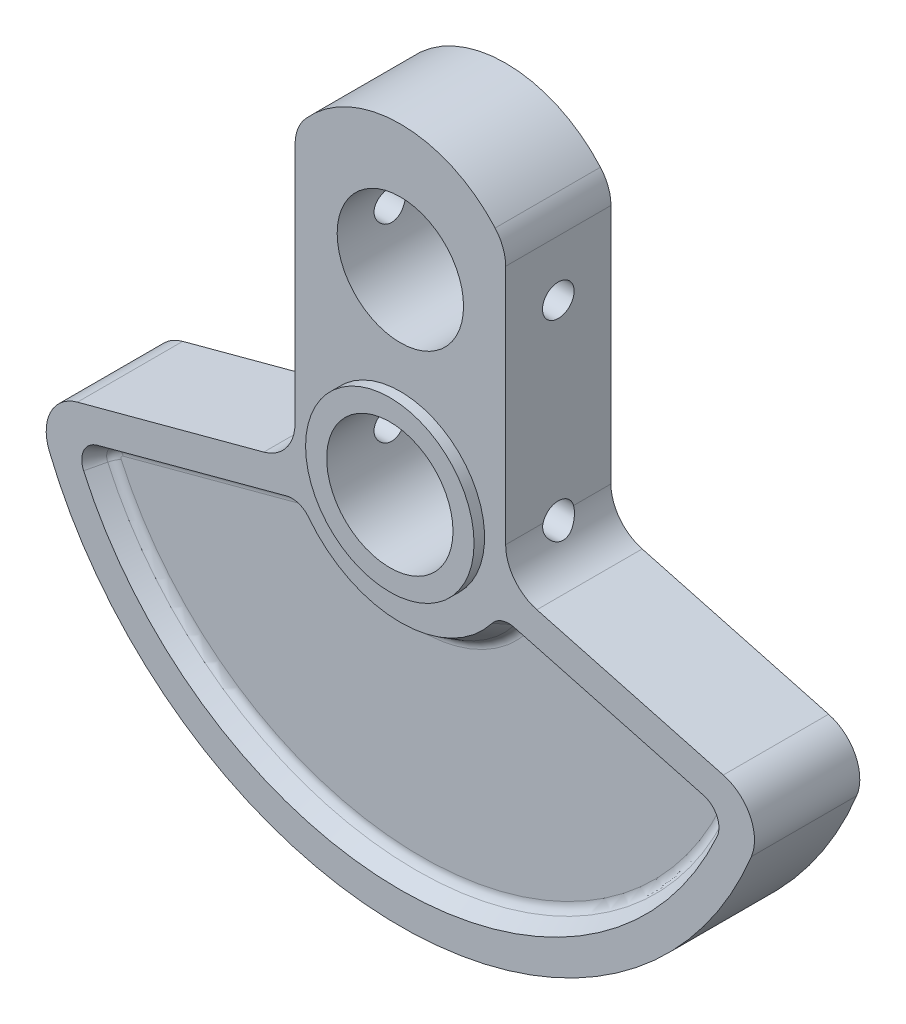
from build123d import *

# Parameters (mm, degrees)
SKETCH1_R            = 6
BOSS_EXTRUDE1_DEPTH  = 5
CUT_EXTRUDE1_DEPTH   = 2
CUT_EXTRUDE1_DRAFT   = -30
FILLET1_R            = 1
MIRROR2_COPY_1_DEPTH = 2
MIRROR2_COPY_1_DRAFT = -30
FILLET1_OF_MIRROR2_R = 1
SKETCH3_R            = 8
SKETCH3_R_2          = 6
BOSS_EXTRUDE2_DEPTH  = 1
SKETCH4_R            = 8
SKETCH4_R_2          = 6
BOSS_EXTRUDE3_DEPTH  = 1
SKETCH5_R            = 1.5
CUT_EXTRUDE2_DEPTH   = 57.883602865


with BuildPart() as part:
    # Sketch1 → Boss-Extrude1 (new, symmetric)
    with BuildSketch(Plane.XY):
        with BuildLine():
            Line((-10, 23.291502622), (-10, 0.389816028))
            ThreePointArc((-10, 0.389816028), (-10.826586639, -2.045229688), (-12.96472382, -3.473887278))
            Line((-12.96472382, -3.473887278), (-30.667194256, -8.217249935))
            ThreePointArc((-30.667194256, -8.217249935), (-33.214466382, -10.301810854), (-33.335907835, -13.591072395))
            ThreePointArc((-33.335907835, -13.591072395), (0, -36), (33.335907835, -13.591072395))
            ThreePointArc((33.335907835, -13.591072395), (33.214466382, -10.301810854), (30.667194256, -8.217249935))
            Line((30.667194256, -8.217249935), (12.96472382, -3.473887278))
            ThreePointArc((12.96472382, -3.473887278), (10.826586639, -2.045229688), (10, 0.389816028))
            Line((10, 0.389816028), (10, 23.291502622))
            ThreePointArc((10, 23.291502622), (9.741657387, 24.705716185), (9, 25.937253933))
            ThreePointArc((9, 25.937253933), (0, 30), (-9, 25.937253933))
            ThreePointArc((-9, 25.937253933), (-9.741657387, 24.705716185), (-10, 23.291502622))
        make_face()
        Circle(SKETCH1_R, mode=Mode.SUBTRACT)
        with Locations((0, 18)):
            Circle(SKETCH1_R, mode=Mode.SUBTRACT)
    extrude(amount=BOSS_EXTRUDE1_DEPTH, both=True)


with BuildPart() as cut_extrude1_tool:
    # Sketch2 → Cut-Extrude1 (with draft: the straight prism first)
    with BuildSketch(Plane.XY.offset(5)):
        with BuildLine():
            ThreePointArc((-28.775190686, -10.816117648), (-30.064835096, -11.891388911), (-30.080620505, -13.570418933))
            ThreePointArc((-30.080620505, -13.570418933), (0, -33), (30.080620505, -13.570418933))
            ThreePointArc((30.080620505, -13.570418933), (30.064835096, -11.891388911), (28.775190686, -10.816117648))
            Line((28.775190686, -10.816117648), (10.81465278, -6.00360602))
            ThreePointArc((10.81465278, -6.00360602), (9.656117125, -6.040925986), (8.712858584, -6.714618031))
            ThreePointArc((8.712858584, -6.714618031), (0, -11), (-8.712858584, -6.714618031))
            ThreePointArc((-8.712858584, -6.714618031), (-9.656117125, -6.040925986), (-10.81465278, -6.00360602))
            Line((-10.81465278, -6.00360602), (-28.775190686, -10.816117648))
        make_face()
    extrude(amount=-CUT_EXTRUDE1_DEPTH)
    # Cut-Extrude1: the draft: its side faces are tilted about the plane it starts from
    cut_extrude1_sides = [cut_extrude1_tool.faces().sort_by_distance(p)[0] for p in [
        (-9.656117125, -6.040925986, 4),
        (-19.794921733, -8.409861834, 4),
        (-30.064835096, -11.891388911, 4),
        (0, -33, 4),
        (30.064835096, -11.891388911, 4),
        (19.794921733, -8.409861834, 4),
        (9.656117125, -6.040925986, 4),
        (0, -11, 4),
    ]]
    draft(cut_extrude1_sides, Plane.XY.offset(5), CUT_EXTRUDE1_DRAFT)


with BuildPart() as part_1:
    add(part.part)

    # Cut-Extrude1: cut by cut_extrude1_tool
    add(cut_extrude1_tool.part, mode=Mode.SUBTRACT)

    # Fillet1
    fillet1_edges = [part_1.edges().sort_by_distance(p)[0] for p in [
        (29.021400058, -12.385935829, 3),
        (0, -31.845299462, 3),
        (-29.021400058, -12.385935829, 3),
        (-19.496063242, -9.525216906, 3),
        (-10.026139506, -7.134734365, 3),
        (0, -12.154700538, 3),
        (10.026139506, -7.134734365, 3),
        (19.496063242, -9.525216906, 3),
    ]]
    fillet(fillet1_edges, radius=FILLET1_R)


with BuildPart() as mirror2_copy_1_tool:
    # Mirror2 copy 1 sketch → Mirror2 copy 1 (with draft: the straight prism first)
    with BuildSketch(Plane(origin=(0, 0, -5), x_dir=(1, 0, 0), z_dir=(0, 0, -1))):
        with BuildLine():
            ThreePointArc((-28.775190686, 10.816117648), (-30.064835096, 11.891388911), (-30.080620505, 13.570418933))
            ThreePointArc((-30.080620505, 13.570418933), (0, 33), (30.080620505, 13.570418933))
            ThreePointArc((30.080620505, 13.570418933), (30.064835096, 11.891388911), (28.775190686, 10.816117648))
            Line((28.775190686, 10.816117648), (10.81465278, 6.00360602))
            ThreePointArc((10.81465278, 6.00360602), (9.656117125, 6.040925986), (8.712858584, 6.714618031))
            ThreePointArc((8.712858584, 6.714618031), (0, 11), (-8.712858584, 6.714618031))
            ThreePointArc((-8.712858584, 6.714618031), (-9.656117125, 6.040925986), (-10.81465278, 6.00360602))
            Line((-10.81465278, 6.00360602), (-28.775190686, 10.816117648))
        make_face()
    extrude(amount=-MIRROR2_COPY_1_DEPTH)
    # Mirror2 copy 1: the draft: its side faces are tilted about the plane it starts from
    mirror2_copy_1_sides = [mirror2_copy_1_tool.faces().sort_by_distance(p)[0] for p in [
        (-9.656117125, -6.040925986, -4),
        (-19.794921733, -8.409861834, -4),
        (-30.064835096, -11.891388911, -4),
        (0, -33, -4),
        (30.064835096, -11.891388911, -4),
        (19.794921733, -8.409861834, -4),
        (9.656117125, -6.040925986, -4),
        (0, -11, -4),
    ]]
    draft(mirror2_copy_1_sides, Plane(origin=(0, 0, -5), x_dir=(1, 0, 0), z_dir=(0, 0, -1)), MIRROR2_COPY_1_DRAFT)


with BuildPart() as part_2:
    add(part_1.part)

    # Mirror2 copy 1: cut by mirror2_copy_1_tool
    add(mirror2_copy_1_tool.part, mode=Mode.SUBTRACT)

    # Fillet1 of Mirror2
    fillet1_of_mirror2_edges = [part_2.edges().sort_by_distance(p)[0] for p in [
        (29.021400058, -12.385935829, -3),
        (0, -31.845299462, -3),
        (-29.021400058, -12.385935829, -3),
        (-19.496063242, -9.525216906, -3),
        (-10.026139506, -7.134734365, -3),
        (0, -12.154700538, -3),
        (10.026139506, -7.134734365, -3),
        (19.496063242, -9.525216906, -3),
    ]]
    fillet(fillet1_of_mirror2_edges, radius=FILLET1_OF_MIRROR2_R)

    # Sketch3 → Boss-Extrude2 (add)
    with BuildSketch(Plane(origin=(0, 0, -5), x_dir=(-1, 0, 0), z_dir=(0, 0, -1))):
        with Locations((0, 18)):
            Circle(SKETCH3_R)
        with Locations((0, 18)):
            Circle(SKETCH3_R_2, mode=Mode.SUBTRACT)
    extrude(amount=BOSS_EXTRUDE2_DEPTH)

    # Sketch4 → Boss-Extrude3 (add)
    with BuildSketch(Plane.XY.offset(5)):
        with Locations(Location((0, 0, 0), (0, 0, 180))):
            Circle(SKETCH4_R)
        Circle(SKETCH4_R_2, mode=Mode.SUBTRACT)
    extrude(amount=BOSS_EXTRUDE3_DEPTH)

    # Sketch5 → Cut-Extrude2 (cut, through all)
    with BuildSketch(Plane.ZY.offset(10)):
        with Locations((0, 18)):
            Circle(SKETCH5_R)
        Circle(SKETCH5_R)
    extrude(amount=-CUT_EXTRUDE2_DEPTH, mode=Mode.SUBTRACT)


solid = part_2.part
